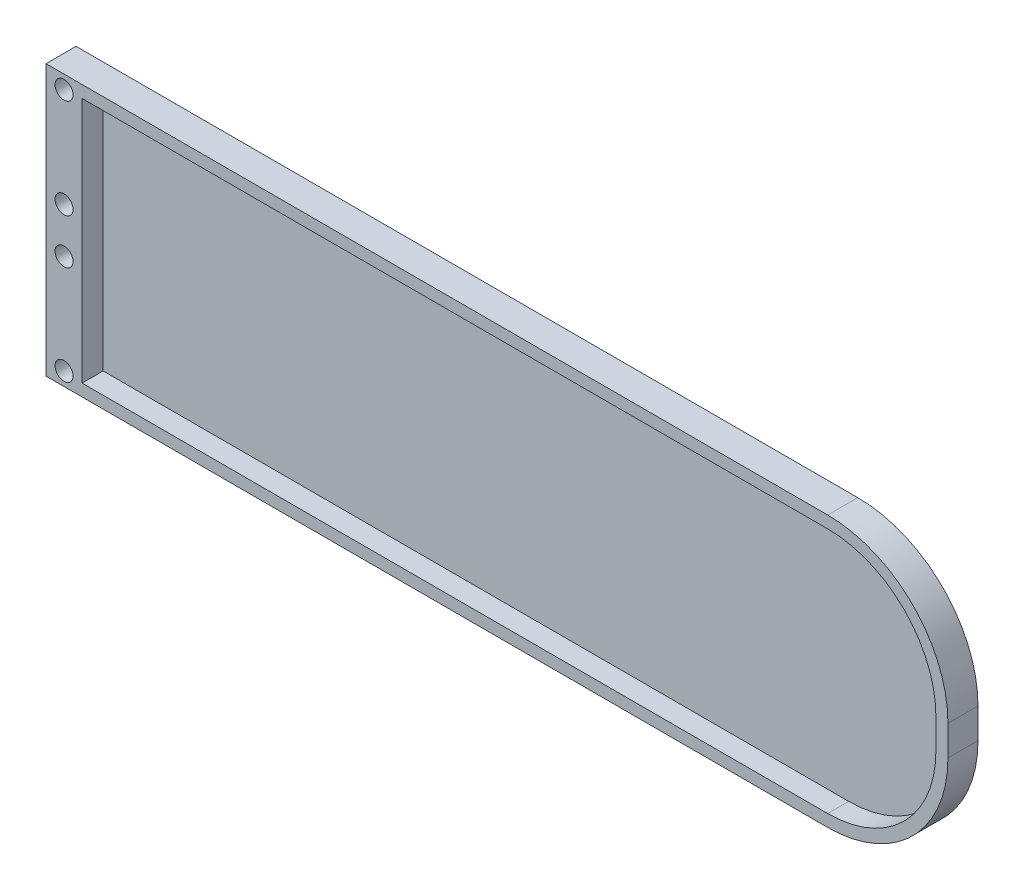
from build123d import *

# Parameters (mm, degrees)
BOSS_EXTRUDE1_DEPTH = 3
SKETCH1_3_R         = 3
BOSS_EXTRUDE2_DEPTH = 10


with BuildPart() as part:
    # Sketch1 → Boss-Extrude1 (new body)
    with BuildSketch(Plane.XY):
        with BuildLine():
            Line((-138, -45), (110, -45))
            ThreePointArc((110, -45), (138.284271247, -33.284271247), (150, -5))
            Line((150, -5), (150, 5))
            ThreePointArc((150, 5), (138.284271247, 33.284271247), (110, 45))
            Line((110, 45), (-138, 45))
            Line((-138, 45), (-138, -45))
        make_face()
    extrude(amount=BOSS_EXTRUDE1_DEPTH)

    # Sketch1_3 → Boss-Extrude2 (add)
    with BuildSketch(Plane.XY):
        with BuildLine():
            ThreePointArc((110, -45), (138.284271247, -33.284271247), (150, -5))
            Line((150, -5), (150, 5))
            ThreePointArc((150, 5), (138.284271247, 33.284271247), (110, 45))
            Line((110, 45), (-150, 45))
            Line((-150, 45), (-150, -45))
            Line((-150, -45), (110, -45))
        make_face()
        with BuildLine():
            Line((110, -41), (-138, -41))
            Line((-138, -41), (-138, 41))
            Line((-138, 41), (110, 41))
            ThreePointArc((110, 41), (135.455844123, 30.455844123), (146, 5))
            Line((146, 5), (146, -5))
            ThreePointArc((146, -5), (135.455844123, -30.455844123), (110, -41))
        make_face(mode=Mode.SUBTRACT)
        with Locations((-144, 7.5)):
            Circle(SKETCH1_3_R, mode=Mode.SUBTRACT)
        with Locations((-144, 40.5)):
            Circle(SKETCH1_3_R, mode=Mode.SUBTRACT)
        with Locations((-144, -40.5)):
            Circle(SKETCH1_3_R, mode=Mode.SUBTRACT)
        with Locations((-144, -7.5)):
            Circle(SKETCH1_3_R, mode=Mode.SUBTRACT)
    extrude(amount=BOSS_EXTRUDE2_DEPTH)


solid = part.part
